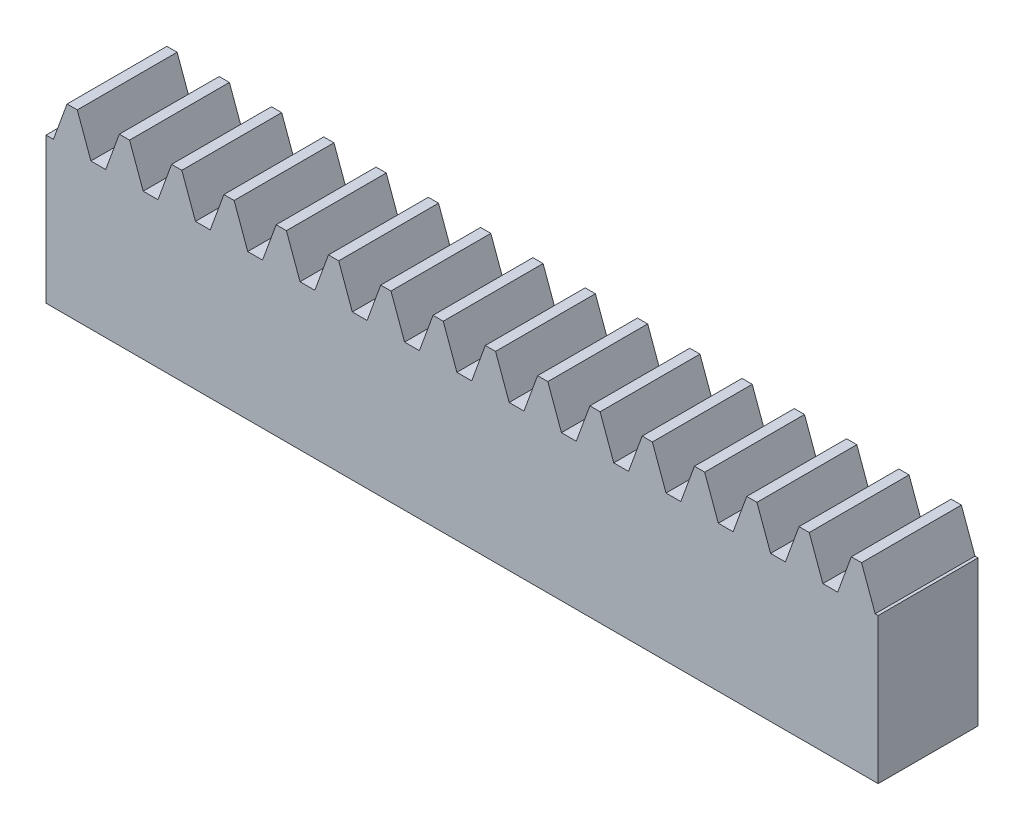
from build123d import *

# Parameters (mm, degrees)
BLANKSKE_W        = 50
BLANKSKE_H        = 11
BLANK_DEPTH       = 6
TOOTHCUTSIM_DEPTH = 52.546095875
TEETHCUTS_COUNT   = 17
TEETHCUTS_PITCH   = 3.14159265


with BuildPart() as part:
    # BlankSke → Blank (new body)
    with BuildSketch(Plane.XY):
        with Locations((25, 5.5)):
            Rectangle(BLANKSKE_W, BLANKSKE_H)
    extrude(amount=-BLANK_DEPTH)

    # TooCutSkeSim → ToothCutSim (cut, through all)
    with BuildSketch(Plane.XY):
        Polygon((0.44443537, 8.75), (-0.44443537, 8.75), (-1.272613241, 11.0254), (1.272613241, 11.0254), align=None)
    toothcutsim = extrude(amount=-TOOTHCUTSIM_DEPTH, mode=Mode.SUBTRACT)

    # TeethCuts: ToothCutSim ×17
    with Locations(*[(i * TEETHCUTS_PITCH, 0, 0) for i in range(1, TEETHCUTS_COUNT)]):
        add(toothcutsim, mode=Mode.SUBTRACT)


solid = part.part
